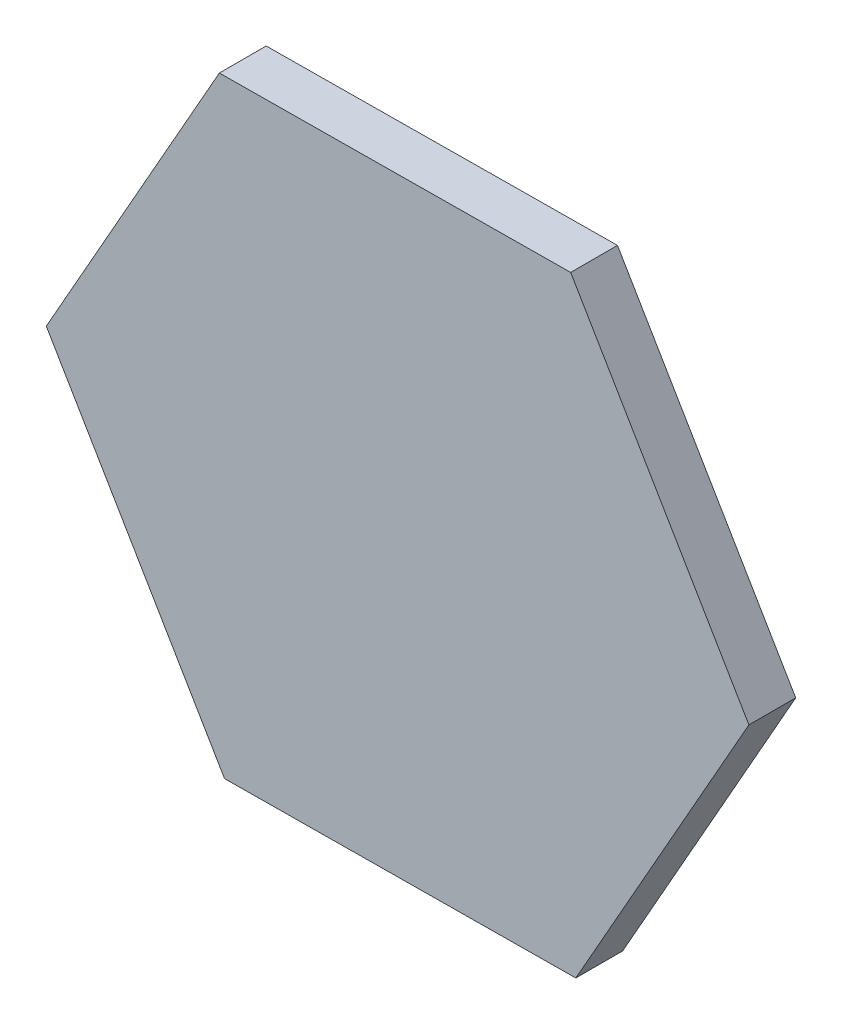
from build123d import *

# Parameters (mm, degrees)
SALIENTE_EXTRUIR1_DEPTH = 1


with BuildPart() as part:
    # Croquis1 → Saliente-Extruir1 (new body)
    with BuildSketch(Plane.XY):
        Polygon((-3.697442402, -6.531634789), (3.807840455, -6.467896443), (7.505282857, 0.063738346), (3.697442402, 6.531634789), (-3.807840455, 6.467896443), (-7.505282857, -0.063738346), align=None)
    extrude(amount=SALIENTE_EXTRUIR1_DEPTH)


solid = part.part
